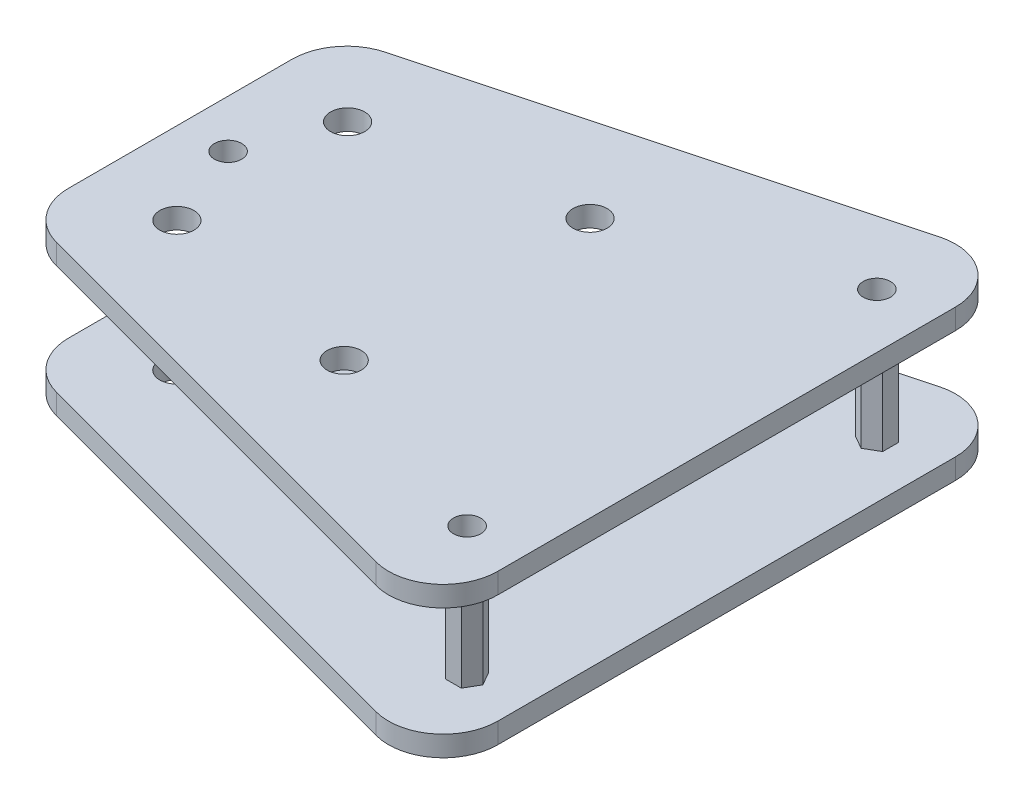
from build123d import *

# Parameters (mm, degrees)
CROQUIS1_R                = 2.5
CROQUIS1_R_2              = 2
SALIENTE_EXTRUIR1_DEPTH   = 22
CROQUIS2_W                = 80
CROQUIS2_H                = 16
CORTAR_EXTRUIR1_DEPTH     = 50
SALIENTE_EXTRUIR2_DEPTH   = 16
SALIENTE_EXTRUIR2_2_DEPTH = 16
SALIENTE_EXTRUIR2_3_DEPTH = 16


with BuildPart() as part:
    # Croquis1 → Saliente-Extruir1 (new body)
    with BuildSketch(Plane(origin=(0, 0, 0), x_dir=(1, 0, 0), z_dir=(0, 1, 0))):
        with BuildLine():
            Line((0, 16.361384096), (0, -16.361384096))
            ThreePointArc((0, -16.361384096), (1.653173278, -21.231475528), (5.929447639, -24.088790706))
            Line((5.929447639, -24.088790706), (69.929447639, -41.237539022))
            ThreePointArc((69.929447639, -41.237539022), (76.870091432, -39.856959134), (80, -33.510132412))
            Line((80, -33.510132412), (80, 33.510132412))
            ThreePointArc((80, 33.510132412), (76.870091432, 39.856959134), (69.929447639, 41.237539022))
            Line((69.929447639, 41.237539022), (5.929447639, 24.088790706))
            ThreePointArc((5.929447639, 24.088790706), (1.653173278, 21.231475528), (0, 16.361384096))
        make_face()
        with Locations((12, 12.5)):
            Circle(CROQUIS1_R, mode=Mode.SUBTRACT)
        with Locations((12, -12.5)):
            Circle(CROQUIS1_R, mode=Mode.SUBTRACT)
        with Locations((42, 18)):
            Circle(CROQUIS1_R, mode=Mode.SUBTRACT)
        with Locations((42, -18)):
            Circle(CROQUIS1_R, mode=Mode.SUBTRACT)
        with Locations((7, 0)):
            Circle(CROQUIS1_R_2, mode=Mode.SUBTRACT)
        with Locations((72, -30)):
            Circle(CROQUIS1_R_2, mode=Mode.SUBTRACT)
        with Locations((72, 30)):
            Circle(CROQUIS1_R_2, mode=Mode.SUBTRACT)
    extrude(amount=SALIENTE_EXTRUIR1_DEPTH)

    # Croquis2 → Cortar-Extruir1 (cut, symmetric)
    with BuildSketch(Plane.XY):
        with Locations((40, 11)):
            Rectangle(CROQUIS2_W, CROQUIS2_H)
    extrude(amount=CORTAR_EXTRUIR1_DEPTH, both=True, mode=Mode.SUBTRACT)


with BuildPart() as body_2:
    # Croquis3 → Saliente-Extruir2 (new body)
    with BuildSketch(Plane(origin=(0, 3, 0), x_dir=(1, 0, 0), z_dir=(0, 1, 0))):
        Polygon((7, -2.309401077), (9, -1.154700538), (9, 1.154700538), (7, 2.309401077), (5, 1.154700538), (5, -1.154700538), align=None)
    extrude(amount=SALIENTE_EXTRUIR2_DEPTH)


with BuildPart() as body_3:
    # Croquis3 → Saliente-Extruir2 2 (new body)
    with BuildSketch(Plane(origin=(0, 3, 0), x_dir=(1, 0, 0), z_dir=(0, 1, 0))):
        Polygon((70.845299462, -32), (73.154700538, -32), (74.309401077, -30), (73.154700538, -28), (70.845299462, -28), (69.690598923, -30), align=None)
    extrude(amount=SALIENTE_EXTRUIR2_2_DEPTH)


with BuildPart() as body_4:
    # Croquis3 → Saliente-Extruir2 3 (new body)
    with BuildSketch(Plane(origin=(0, 3, 0), x_dir=(1, 0, 0), z_dir=(0, 1, 0))):
        Polygon((74, 28.845299462), (74, 31.154700538), (72, 32.309401077), (70, 31.154700538), (70, 28.845299462), (72, 27.690598923), align=None)
    extrude(amount=SALIENTE_EXTRUIR2_3_DEPTH)


solid = Compound([part.part, body_2.part, body_3.part, body_4.part])
